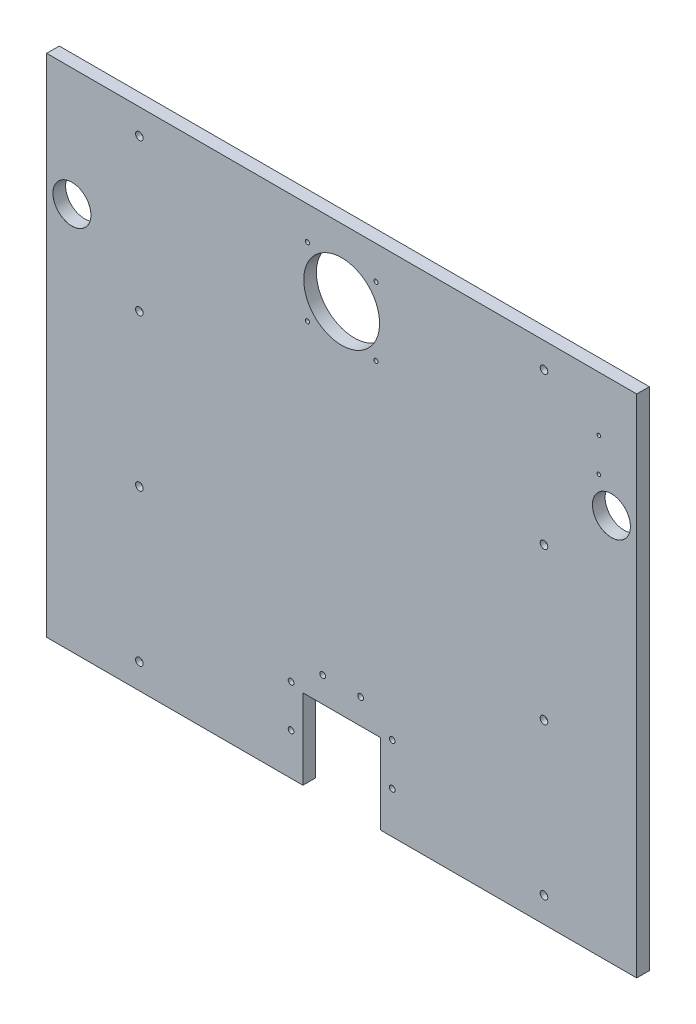
from build123d import *

# Parameters (mm, degrees)
SKETCH_1_W                   = 700
SKETCH_1_H                   = 600
EXTRUDE_1_DEPTH              = 15
SKETCH_2_W                   = 92
SKETCH_2_H                   = 95
CUT_EXTRUDE_1_DEPTH          = 16
HOLE_WIZARD_5_0_5_1_D        = 5
HOLE_WIZARD_6_8_6_8_1_D      = 6.8
HOLE_WIZARD_6_8_6_8_1_DEPTH  = 15
HOLE_WIZARD_M8_1_D           = 9
HOLE_WIZARD_M8_1_DEPTH       = 15
HOLE_WIZARD_M8_1_CBORE_D     = 15
HOLE_WIZARD_M8_1_CBORE_DEPTH = 9
HOLE_WIZARD_4_2_4_2_1_D      = 4.2
HOLE_WIZARD_4_2_4_2_1_DEPTH  = 12.4
HOLE_WIZARD_4_2_4_2_1_TIP    = 1.2618073
HOLE_WIZARD_M80_1_D          = 90
HOLE_WIZARD_M80_1_DEPTH      = 15
HOLE_WIZARD_M39_1_D          = 45
CHAMFER_1_SIZE               = 0.025


with BuildPart() as part:
    # 草图1 → 凸台-拉伸1 (new body)
    with BuildSketch(Plane(origin=(0, 0, -190), x_dir=(-1, 0, 0), z_dir=(0, 0, -1))):
        with Locations((0, 1520)):
            Rectangle(SKETCH_1_W, SKETCH_1_H)
    extrude(amount=-EXTRUDE_1_DEPTH)

    # 草图2 → 切除-拉伸1 (cut, through all)
    with BuildSketch(Plane.XY.offset(-175)):
        with Locations((0, 1267.5)):
            Rectangle(SKETCH_2_W, SKETCH_2_H)
    extrude(amount=-CUT_EXTRUDE_1_DEPTH, mode=Mode.SUBTRACT)

    # Ø5.0 (5) 直径孔1 (through all)
    with Locations(Plane.XY.offset(-175)):
        with Locations((-40.658639918, 1699.341360082), (40.658639918, 1699.341360082), (40.658639918, 1780.658639918), (-40.658639918, 1780.658639918)):
            Hole(HOLE_WIZARD_5_0_5_1_D / 2)

    # Ø6.8 (6.8) 直径孔1
    with Locations(Plane.XY.offset(-175)):
        with Locations((60, 1319.472182943), (60, 1269.472182943), (-60, 1269.472182943), (-60, 1319.472182943), (22.5, 1345), (-22.5, 1345)):
            Hole(HOLE_WIZARD_6_8_6_8_1_D / 2, depth=HOLE_WIZARD_6_8_6_8_1_DEPTH)

    # M8 六角头螺栓的柱形沉头孔1
    with Locations(Plane(origin=(0, 0, -190), x_dir=(-1, 0, 0), z_dir=(0, 0, -1))):
        with Locations((240, 1250), (240, 1430), (240, 1610), (240, 1790), (-240, 1250), (-240, 1430), (-240, 1610), (-240, 1790)):
            CounterBoreHole(HOLE_WIZARD_M8_1_D / 2, HOLE_WIZARD_M8_1_CBORE_D / 2, HOLE_WIZARD_M8_1_CBORE_DEPTH, depth=HOLE_WIZARD_M8_1_DEPTH)

    # Ø4.2 (4.2) 直径孔1
    with Locations(Plane.XY.offset(-175)):
        with Locations((305, 1715), (305, 1755)):
            Hole(HOLE_WIZARD_4_2_4_2_1_D / 2, depth=HOLE_WIZARD_4_2_4_2_1_DEPTH)
            with Locations((0, 0, -(HOLE_WIZARD_4_2_4_2_1_DEPTH + HOLE_WIZARD_4_2_4_2_1_TIP / 2))):  # 118° drill point
                Cone(0, HOLE_WIZARD_4_2_4_2_1_D / 2, HOLE_WIZARD_4_2_4_2_1_TIP, mode=Mode.SUBTRACT)

    # M80 间隙孔1
    with Locations(Plane(origin=(0, 0, -190), x_dir=(-1, 0, 0), z_dir=(0, 0, -1))):
        with Locations((0, 1740)):
            Hole(HOLE_WIZARD_M80_1_D / 2, depth=HOLE_WIZARD_M80_1_DEPTH)

    # M39 间隙孔1 (through all)
    with Locations(Plane.XY.offset(-175)):
        with Locations((-320, 1680), (320, 1680)):
            Hole(HOLE_WIZARD_M39_1_D / 2)

    # 倒角1
    chamfer_1_edges = [part.edges().sort_by_distance(p)[0] for p in [
        (342.5, 1680, -175),
        (-297.5, 1680, -175),
    ]]
    chamfer(chamfer_1_edges, length=CHAMFER_1_SIZE)


solid = part.part
